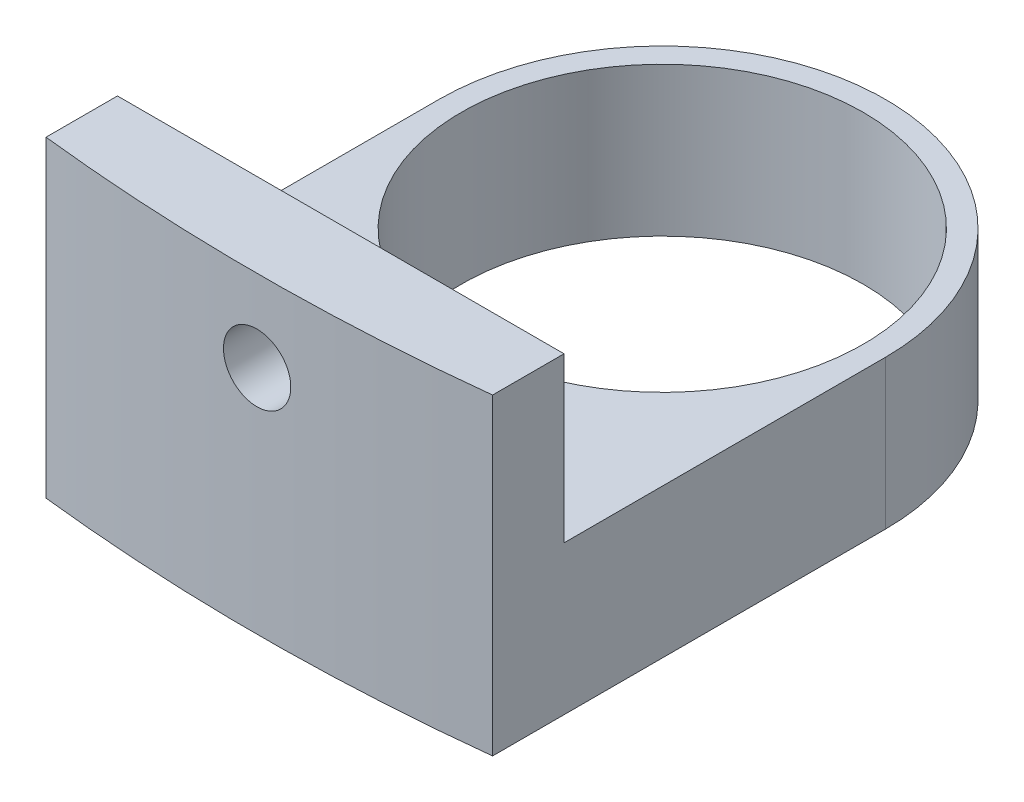
from build123d import *

# Parameters (mm, degrees)
SKETCH2_R           = 9.525
SKETCH2_R_2         = 8.5725
BOSS_EXTRUDE1_DEPTH = 3.175
BOSS_EXTRUDE2_DEPTH = 3.175
BOSS_EXTRUDE3_DEPTH = 10.16
SKETCH5_R           = 1.4351
CUT_EXTRUDE1_DEPTH  = 19.05


with BuildPart() as part:
    # Sketch2 → Boss-Extrude1 (new body, symmetric)
    with BuildSketch(Plane(origin=(0, 0, 0), x_dir=(1, 0, 0), z_dir=(0, 1, 0))):
        Circle(SKETCH2_R)
        Circle(SKETCH2_R_2, mode=Mode.SUBTRACT)
    extrude(amount=BOSS_EXTRUDE1_DEPTH, both=True)

    # Sketch3 → Boss-Extrude2 (add, symmetric)
    with BuildSketch(Plane(origin=(0, 0, 0), x_dir=(1, 0, 0), z_dir=(0, 1, 0))):
        with BuildLine():
            Line((-9.525, 0), (-9.525, -16.764))
            ThreePointArc((-9.525, -16.764), (0, -17.294810057), (9.525, -16.764))
            Line((9.525, -16.764), (9.525, 0))
            ThreePointArc((9.525, 0), (0, -9.525), (-9.525, 0))
        make_face()
    extrude(amount=BOSS_EXTRUDE2_DEPTH, both=True)

    # Sketch4 → Boss-Extrude3 (add)
    with BuildSketch(Plane(origin=(0, 0, 0), x_dir=(1, 0, 0), z_dir=(0, 1, 0))):
        with BuildLine():
            Line((-9.525, -16.764), (-9.525, -13.716))
            Line((-9.525, -13.716), (9.525, -13.716))
            Line((9.525, -13.716), (9.525, -16.764))
            ThreePointArc((9.525, -16.764), (0, -17.294810057), (-9.525, -16.764))
        make_face()
    extrude(amount=BOSS_EXTRUDE3_DEPTH)

    # Sketch5 → Cut-Extrude1 (cut)
    with BuildSketch(Plane(origin=(0, 0, 13.716), x_dir=(-1, 0, 0), z_dir=(0, 0, -1))):
        with Locations((0, 6.6675)):
            Circle(SKETCH5_R)
    extrude(amount=-CUT_EXTRUDE1_DEPTH, mode=Mode.SUBTRACT)


solid = part.part
